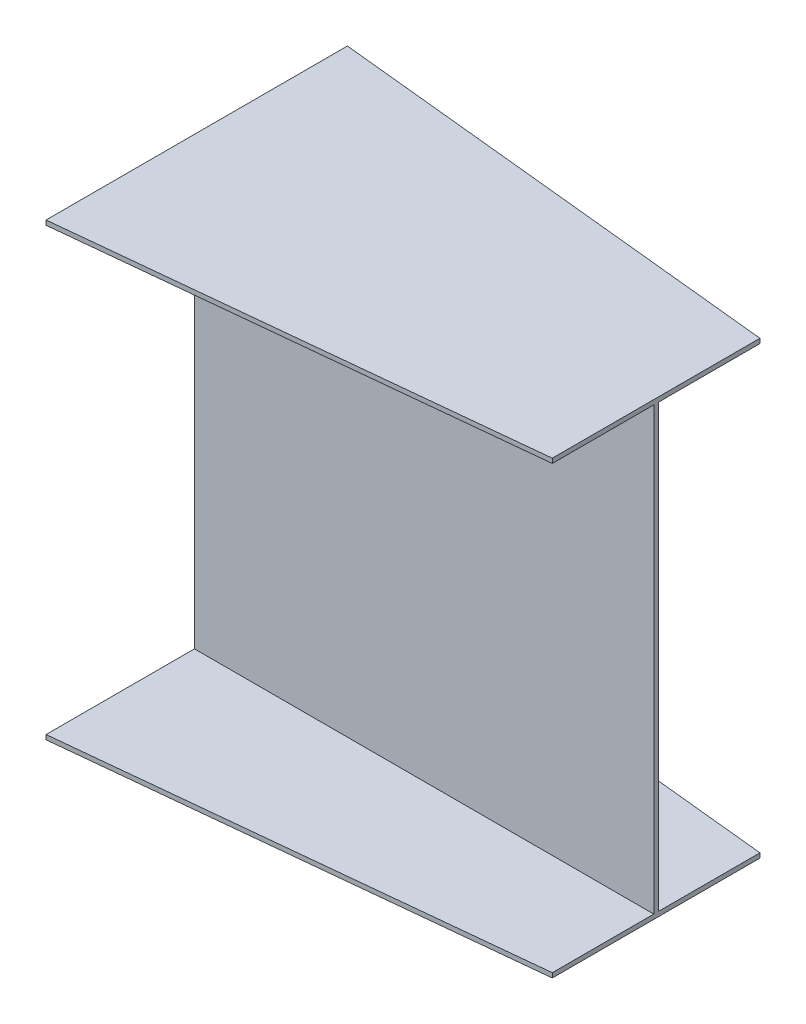
from build123d import *


with BuildPart() as part:
    # Sketch1 → Loft l1 section 0
    with BuildSketch(Plane(origin=(0, 0, 0), x_dir=(0, 0, -1), z_dir=(1, 0, 0))):
        Polygon((-333, 490), (323, 490), (323, 480), (0, 480), (0, -480), (323, -480), (323, -490), (-333, -490), (-333, -480), (-10, -480), (-10, 480), (-333, 480), align=None)
    # Sketch4 → Loft l1 section 1
    with BuildSketch(Plane(origin=(1000, 0, -1000), x_dir=(0, 0, 1), z_dir=(-1, 0, 0))):
        Polygon((779, 490), (1231, 490), (1231, 480), (1010, 480), (1010, -480), (1231, -480), (1231, -490), (779, -490), (779, -480), (1000, -480), (1000, 480), (779, 480), align=None)
    loft()


solid = part.part
